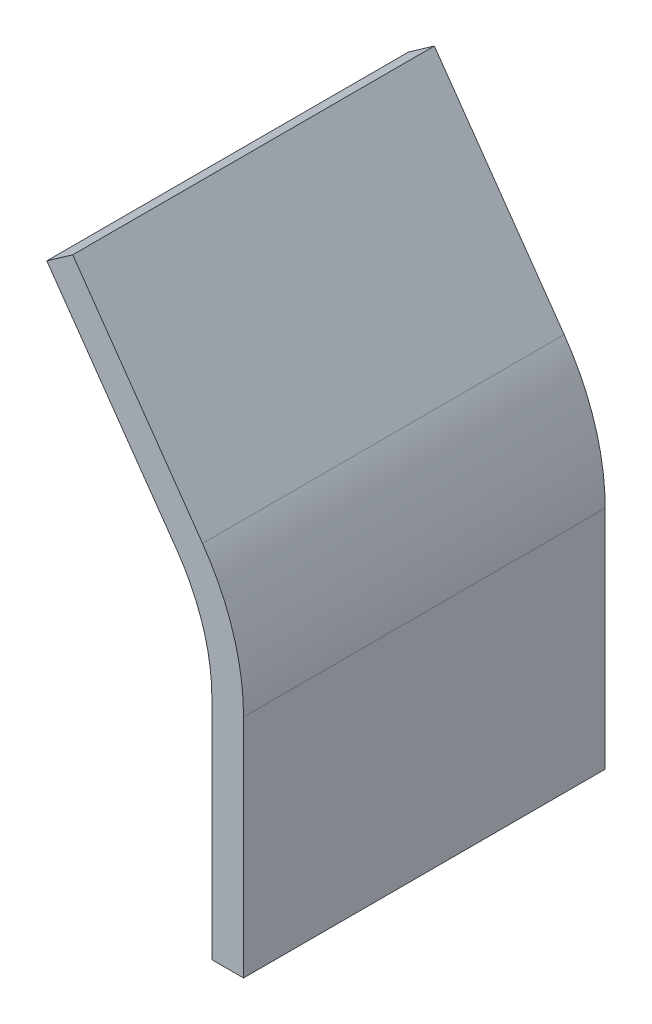
from build123d import *

# Parameters (mm, degrees)
EXTRUIR_L_MINA1_DEPTH = 20


with BuildPart() as part:
    # Croquis1 → Extruir-Lámina1 (new body, symmetric)
    with BuildSketch(Plane.XY):
        with BuildLine():
            Line((-18.897074708, 59.824622078), (-4.536226315, 39.360848393))
            ThreePointArc((-4.536226315, 39.360848393), (-1.161015729, 32.530128082), (0, 25))
            Line((0, 25), (0, 0))
            Line((0, 0), (-3.5, 0))
            Line((-3.5, 0), (-3.5, 25))
            ThreePointArc((-3.5, 25), (-4.498473527, 31.475910151), (-7.401154631, 37.350329618))
            Line((-7.401154631, 37.350329618), (-21.762003023, 57.814103303))
            Line((-21.762003023, 57.814103303), (-18.897074708, 59.824622078))
        make_face()
    extrude(amount=EXTRUIR_L_MINA1_DEPTH, both=True)


solid = part.part
